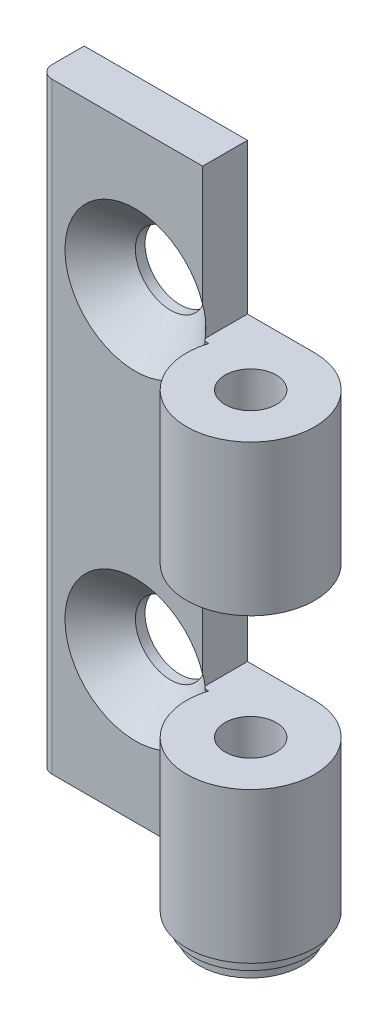
from build123d import *

# Parameters (mm, degrees)
SKETCH1_W               = 5
SKETCH1_H               = 47
SKETCH2_W               = 18
SKETCH2_H               = 47
BOSS_EXTRUDE1_DEPTH     = 3.5
CUT_EXTRUDE1_DEPTH      = 47
CUT_EXTRUDE1_DEPTH_BACK = 47
SKETCH3_W               = 94
SKETCH3_H               = 94
SKETCH5_W               = 2
SKETCH5_H               = 53.4
CUT_EXTRUDE2_DEPTH      = 23.5
CUT_EXTRUDE2_DEPTH_BACK = 23.5


with BuildPart() as part:
    # Sketch1 → Revolve1 (revolve)
    with BuildSketch(Plane.XY):
        with Locations((2.5, 0)):
            Rectangle(SKETCH1_W, SKETCH1_H)
    revolve(axis=Axis((0, -23.5, 0), (0, 1, 0)))

    # Sketch2 → Boss-Extrude1 (add)
    with BuildSketch(Plane.XY.offset(-5)):
        with Locations((-9, 0)):
            Rectangle(SKETCH2_W, SKETCH2_H)
    extrude(amount=BOSS_EXTRUDE1_DEPTH)

    # Sketch3 → Cut-Extrude1 (cut, two sides: drawn at the far end of the back side and taken through both)
    with BuildSketch(Plane.XY.offset(-CUT_EXTRUDE1_DEPTH_BACK)):
        Rectangle(SKETCH3_W, SKETCH3_H)
        Polygon((-18, -23.5), (5, -23.5), (5, -11.75), (-5.25, -11.75), (-5.25, 0), (5, 0), (5, 11.75), (-5.25, 11.75), (-5.25, 23.5), (-18, 23.5), align=None, mode=Mode.SUBTRACT)
    extrude(amount=CUT_EXTRUDE1_DEPTH + CUT_EXTRUDE1_DEPTH_BACK, mode=Mode.SUBTRACT)

    # Sketch4 → Revolve2 (revolve)
    with BuildSketch(Plane.XY):
        Polygon((0, -23.5), (4.5, -23.5), (4.5, -24.35), (4, -24.35), (4, -25.2), (0, -25.2), align=None)
    revolve(axis=Axis((0, -25.2, 0), (0, 1, 0)))

    # Sketch5 → Cut-Revolve1 (revolve, cut)
    with BuildSketch(Plane.XY):
        with Locations((1, 0)):
            Rectangle(SKETCH5_W, SKETCH5_H)
    revolve(axis=Axis((0, -26.7, 0), (0, 1, 0)), mode=Mode.SUBTRACT)

    # Sketch6 → Cut-Revolve2 (revolve, cut)
    with BuildSketch(Plane(origin=(-10.5, 0, 0), x_dir=(0, 0, -1), z_dir=(1, 0, 0))):
        Polygon((5, -12.5), (5, -15.25), (4.25, -15.25), (1.5, -18), (1.5, -12.5), align=None)
    revolve(axis=Axis((-10.5, -12.5, -1.5), (0, 0, -1)), mode=Mode.SUBTRACT)

    # Sketch7 → Cut-Revolve3 (revolve, cut)
    with BuildSketch(Plane(origin=(-10.5, 0, 0), x_dir=(0, 0, -1), z_dir=(1, 0, 0))):
        Polygon((5, 12.5), (5, 9.75), (4.25, 9.75), (1.5, 7), (1.5, 12.5), align=None)
    revolve(axis=Axis((-10.5, 12.5, -1.5), (0, 0, -1)), mode=Mode.SUBTRACT)

    # Sketch8 → Cut-Extrude2 (cut, two sides: drawn at the far end of the back side and taken through both)
    with BuildSketch(Plane(origin=(0, 0, 0), x_dir=(1, 0, 0), z_dir=(0, 1, 0)).offset(-CUT_EXTRUDE2_DEPTH_BACK)):
        with BuildLine():
            Line((-18, 2.5), (-18, 1.5))
            Line((-18, 1.5), (-17, 1.5))
            ThreePointArc((-17, 1.5), (-17.707106781, 1.792893219), (-18, 2.5))
        make_face()
    extrude(amount=CUT_EXTRUDE2_DEPTH + CUT_EXTRUDE2_DEPTH_BACK, mode=Mode.SUBTRACT)


solid = part.part
